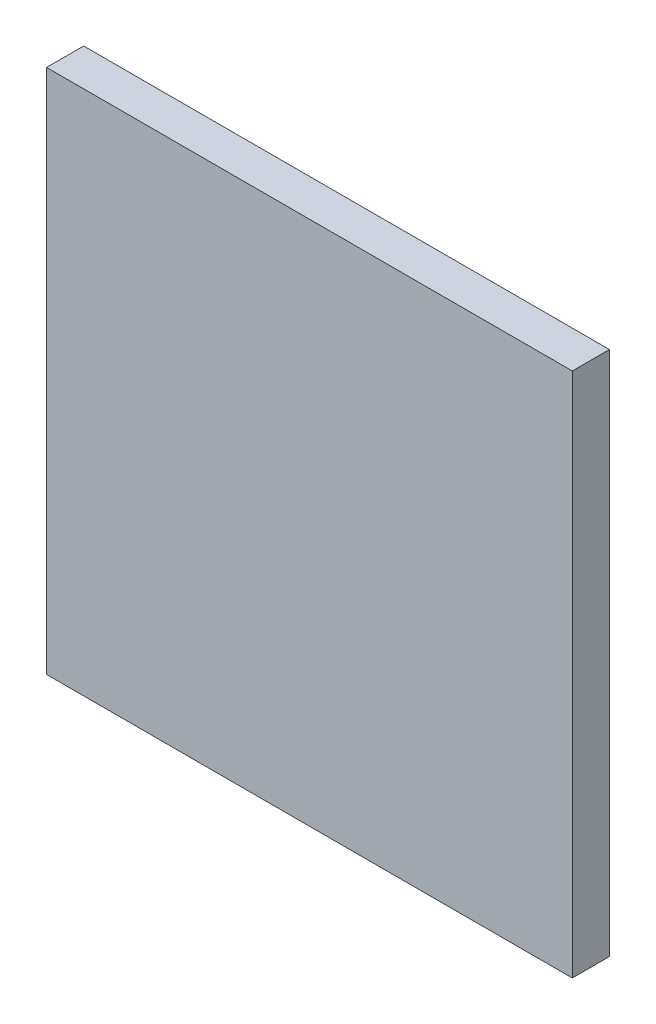
from build123d import *

# Parameters (mm, degrees)
SKETCH1_W           = 17
SKETCH1_H           = 17
BOSS_EXTRUDE1_DEPTH = 1.2


with BuildPart() as part:
    # Sketch1 → Boss-Extrude1 (new body)
    with BuildSketch(Plane.XY):
        Rectangle(SKETCH1_W, SKETCH1_H)
    extrude(amount=BOSS_EXTRUDE1_DEPTH)


solid = part.part
